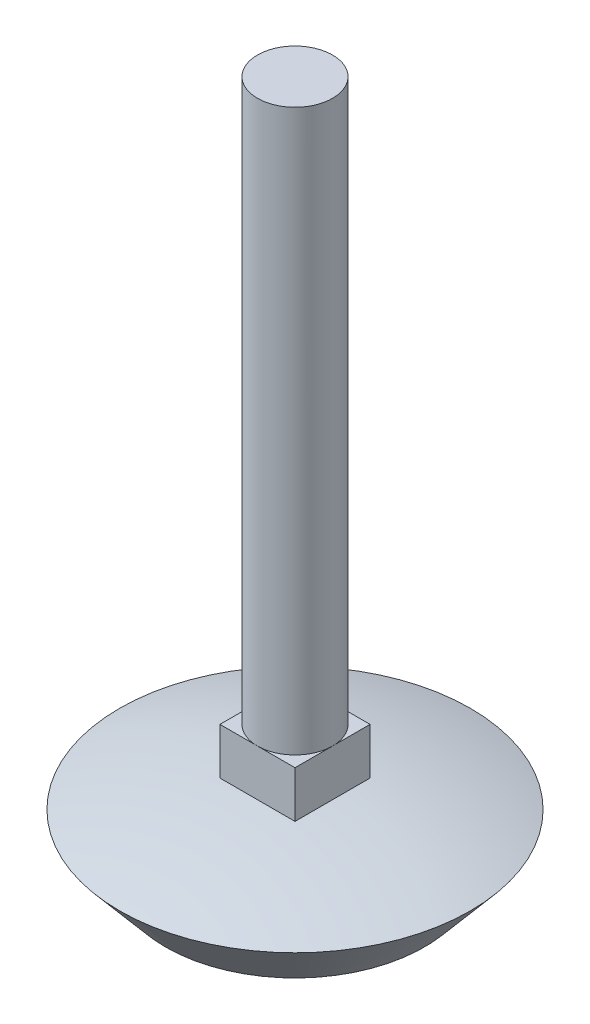
from build123d import *

# Parameters (mm, degrees)
EXTRUDE1_DEPTH = 4.6736


with BuildPart() as part:
    # Sketch1 → Revolve1 (revolve)
    with BuildSketch(Plane.XY):
        with BuildLine():
            Line((152.4, 939.2412), (152.4, 853.44))
            Line((152.4, 853.44), (136.271, 853.44))
            Line((136.271, 853.44), (130.556, 860.202760353))
            ThreePointArc((130.556, 860.202760353), (139.032835502, 862.449078304), (147.726400001, 863.6))
            Line((147.726400001, 863.6), (147.726400001, 939.2412))
            Line((147.726400001, 939.2412), (152.4, 939.2412))
        make_face()
    revolve(axis=Axis((152.4, 939.2412, 0), (0, -1, 0)))

    # Sketch2 → Extrude1 (add, symmetric)
    with BuildSketch(Plane.XY):
        Polygon((157.073600006, 863.600000001), (157.073599999, 869.3912), (147.726400001, 869.3912), (147.726400001, 863.6), align=None)
    extrude(amount=EXTRUDE1_DEPTH, both=True)


solid = part.part
